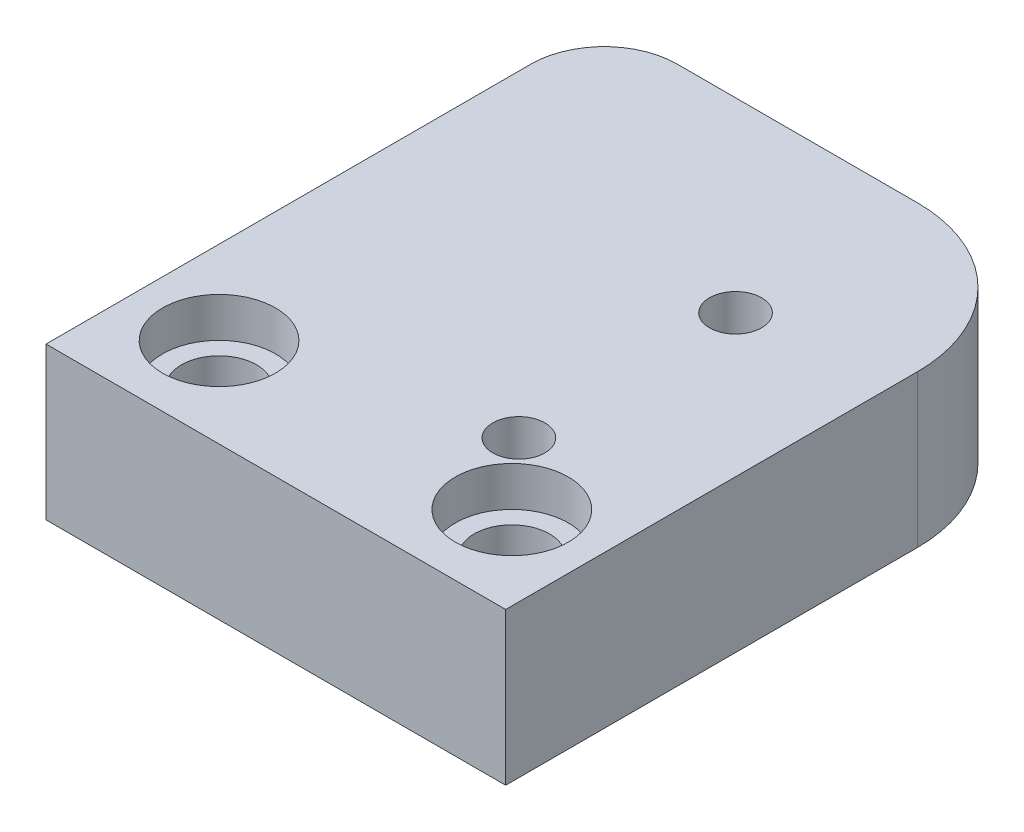
from build123d import *

# Parameters (mm, degrees)
SKETCH1_W                                           = 19.939
SKETCH1_H                                           = 24.2062
BOSS_EXTRUDE1_DEPTH                                 = 6.604
F_4_40_TAPPED_HOLE1_D                               = 2.2606
F_4_40_TAPPED_HOLE1_DEPTH                           = 6.604
CBORE_FOR_4_BINDING_HEAD_MACHINE_SCREW2_D           = 3.2639
CBORE_FOR_4_BINDING_HEAD_MACHINE_SCREW2_CBORE_D     = 4.9022
CBORE_FOR_4_BINDING_HEAD_MACHINE_SCREW2_CBORE_DEPTH = 1.7272
FILLET1_R                                           = 6.35
FILLET2_R                                           = 3.175


with BuildPart() as part:
    # Sketch1 → Boss-Extrude1 (new body)
    with BuildSketch(Plane(origin=(0, 0, 0), x_dir=(1, 0, 0), z_dir=(0, 1, 0))):
        with Locations((0, 12.1031)):
            Rectangle(SKETCH1_W, SKETCH1_H)
    extrude(amount=BOSS_EXTRUDE1_DEPTH)

    # #4-40 Tapped Hole1
    with Locations(Plane(origin=(0, 6.604, 0), x_dir=(1, 0, 0), z_dir=(0, 1, 0))):
        with Locations((3.81, 16.129), (3.81, 6.731)):
            Hole(F_4_40_TAPPED_HOLE1_D / 2, depth=F_4_40_TAPPED_HOLE1_DEPTH)

    # CBORE for #4 Binding Head Machine Screw2 (through all)
    with Locations(Plane(origin=(0, 6.604, 0), x_dir=(1, 0, 0), z_dir=(0, 1, 0))):
        with Locations((-6.35, 3.8862), (6.35, 3.8862)):
            CounterBoreHole(CBORE_FOR_4_BINDING_HEAD_MACHINE_SCREW2_D / 2, CBORE_FOR_4_BINDING_HEAD_MACHINE_SCREW2_CBORE_D / 2, CBORE_FOR_4_BINDING_HEAD_MACHINE_SCREW2_CBORE_DEPTH)

    # Fillet1
    fillet1_edges = [part.edges().sort_by_distance(p)[0] for p in [
        (9.9695, 3.302, -24.2062),
    ]]
    fillet(fillet1_edges, radius=FILLET1_R)

    # Fillet2
    fillet2_edges = [part.edges().sort_by_distance(p)[0] for p in [
        (-9.9695, 3.302, -24.2062),
    ]]
    fillet(fillet2_edges, radius=FILLET2_R)


solid = part.part
